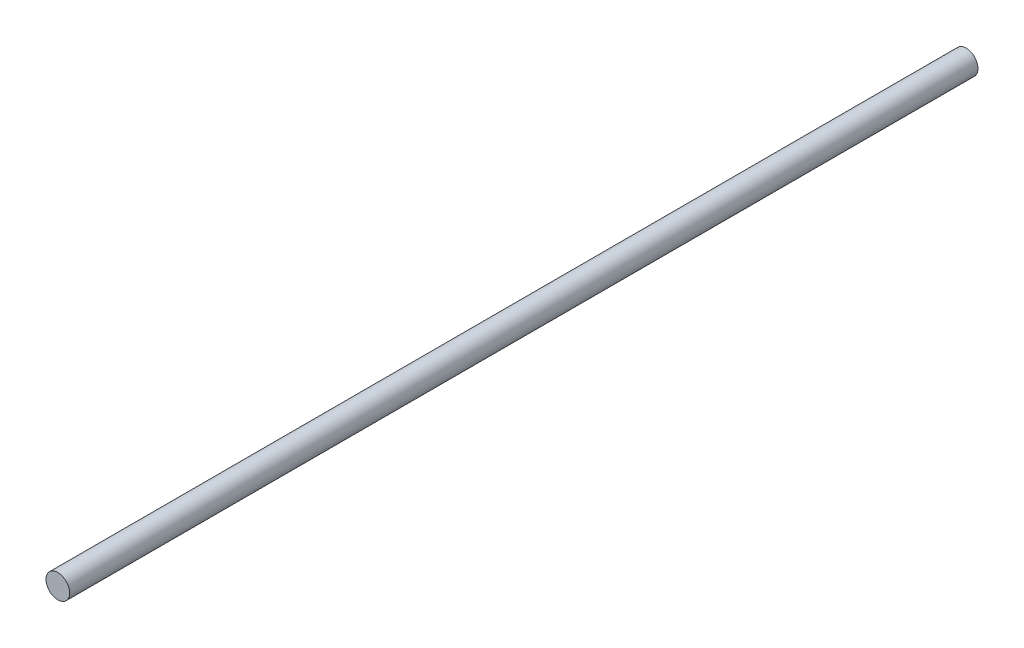
from build123d import *

# Parameters (mm, degrees)
SKETCH1_R           = 3
BOSS_EXTRUDE1_DEPTH = 230


with BuildPart() as part:
    # Sketch1 → Boss-Extrude1 (new body)
    with BuildSketch(Plane.XY):
        Circle(SKETCH1_R)
    extrude(amount=BOSS_EXTRUDE1_DEPTH)


solid = part.part
